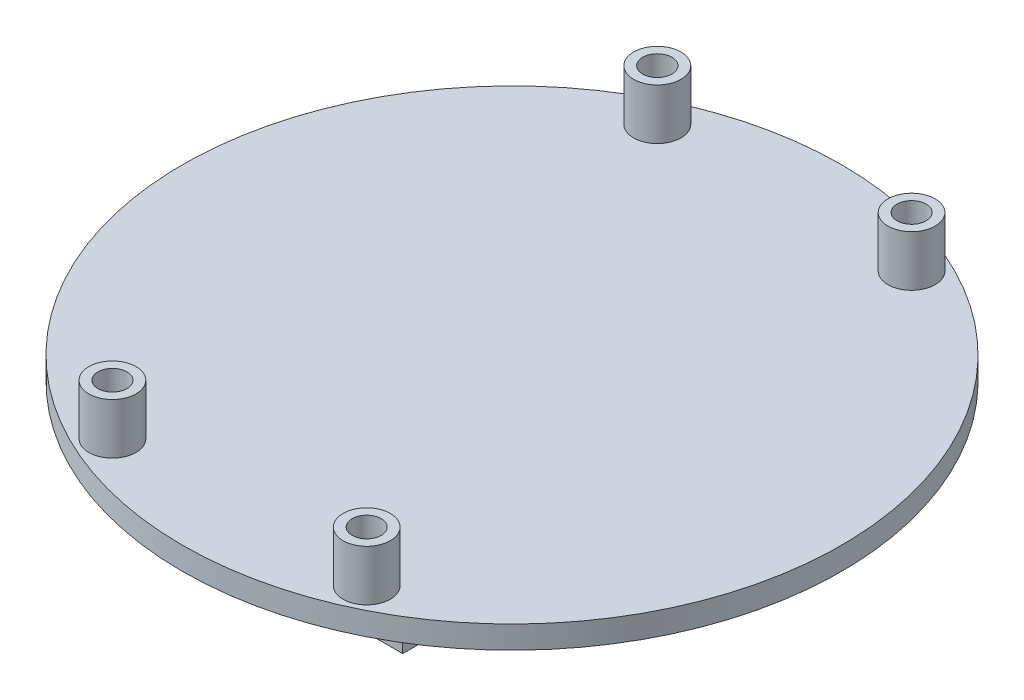
from build123d import *

# Parameters (mm, degrees)
CROQUIS1_R              = 36.29
SALIENTE_EXTRUIR1_DEPTH = 1.25
CROQUIS2_W              = 29.94
CROQUIS2_H              = 54.01
CROQUIS2_W_2            = 27.94
CROQUIS2_H_2            = 52.01
SALIENTE_EXTRUIR2_DEPTH = 5
CROQUIS3_R              = 2.60731142
CROQUIS3_R_2            = 1.60731142
CROQUIS3_R_3            = 2.6
CROQUIS3_R_4            = 1.6
CROQUIS3_R_5            = 2.600000001
CROQUIS3_R_6            = 1.600000001
SALIENTE_EXTRUIR3_DEPTH = 5.59
CROQUIS3_3_R            = 1.6
CROQUIS3_3_R_2          = 1.600000001
CROQUIS3_3_R_3          = 1.60731142
CORTAR_EXTRUIR1_DEPTH   = 52.866927806


with BuildPart() as part:
    # Croquis1 → Saliente-Extruir1 (new, symmetric)
    with BuildSketch(Plane(origin=(0, 0, 0), x_dir=(1, 0, 0), z_dir=(0, 1, 0))):
        Circle(CROQUIS1_R)
    extrude(amount=SALIENTE_EXTRUIR1_DEPTH, both=True)

    # Croquis2 → Saliente-Extruir2 (add)
    with BuildSketch(Plane.XZ.offset(1.25)):
        Rectangle(CROQUIS2_W, CROQUIS2_H)
        Rectangle(CROQUIS2_W_2, CROQUIS2_H_2, mode=Mode.SUBTRACT)
    extrude(amount=SALIENTE_EXTRUIR2_DEPTH)

    # Croquis3 → Saliente-Extruir3 (add)
    # profile 1 of 4: a face of its own
    with BuildSketch(Plane(origin=(0, 1.25, 0), x_dir=(1, 0, 0), z_dir=(0, 1, 0))):
        with Locations((-14, 30)):
            Circle(CROQUIS3_R)
        with Locations((-14, 30)):
            Circle(CROQUIS3_R_2, mode=Mode.SUBTRACT)
    # profile 2 of 4: a face of its own
    with BuildSketch(Plane(origin=(0, 1.25, 0), x_dir=(1, 0, 0), z_dir=(0, 1, 0))):
        with Locations((14, 30)):
            Circle(CROQUIS3_R_3)
        with Locations((14, 30)):
            Circle(CROQUIS3_R_4, mode=Mode.SUBTRACT)
    # profile 3 of 4: a face of its own
    with BuildSketch(Plane(origin=(0, 1.25, 0), x_dir=(1, 0, 0), z_dir=(0, 1, 0))):
        with Locations((-14.000000001, -30)):
            Circle(CROQUIS3_R_5)
        with Locations((-14.000000001, -30)):
            Circle(CROQUIS3_R_6, mode=Mode.SUBTRACT)
    # profile 4 of 4: a face of its own
    with BuildSketch(Plane(origin=(0, 1.25, 0), x_dir=(1, 0, 0), z_dir=(0, 1, 0))):
        with Locations((13.999999999, -30)):
            Circle(CROQUIS3_R_5)
        with Locations((13.999999999, -30)):
            Circle(CROQUIS3_R_6, mode=Mode.SUBTRACT)
    extrude(amount=SALIENTE_EXTRUIR3_DEPTH)

    # Croquis3_3 → Cortar-Extruir1 (cut, through all)
    with BuildSketch(Plane(origin=(0, 1.25, 0), x_dir=(1, 0, 0), z_dir=(0, 1, 0))):
        with Locations((14, 30)):
            Circle(CROQUIS3_3_R)
        with Locations((13.999999999, -30)):
            Circle(CROQUIS3_3_R_2)
        with Locations((-14.000000001, -30)):
            Circle(CROQUIS3_3_R_2)
        with Locations((-14, 30)):
            Circle(CROQUIS3_3_R_3)
    extrude(amount=-CORTAR_EXTRUIR1_DEPTH, mode=Mode.SUBTRACT)


solid = part.part
